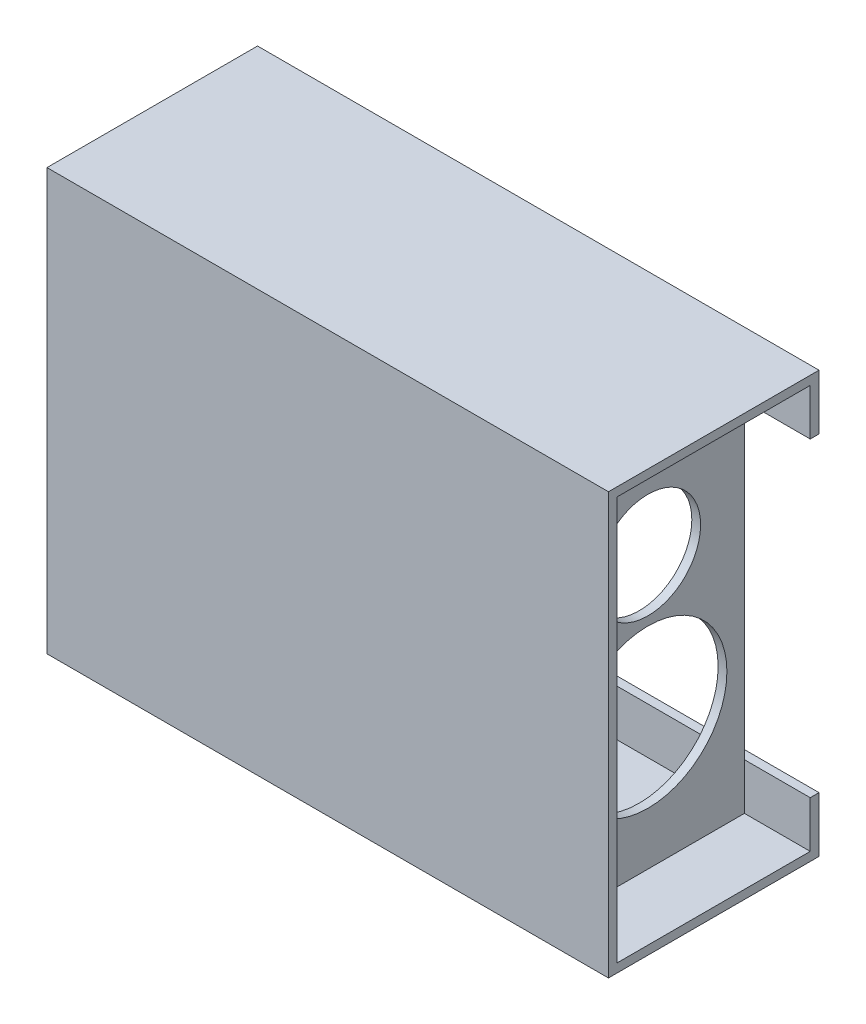
from build123d import *

# Parameters (mm, degrees)
SKETCH2_W                      = 152.4
SKETCH2_H                      = 76.2
BOSS_EXTRUDE1_DEPTH            = 3.175
SKETCH3_W                      = 152.4
SKETCH3_H                      = 76.2
SKETCH3_W_2                    = 146.05
SKETCH3_H_2                    = 69.85
BOSS_EXTRUDE2_DEPTH            = 71.4375
SKETCH4_W                      = 152.4
SKETCH4_H                      = 76.2
BOSS_EXTRUDE3_DEPTH            = 3.175
SKETCH5_W                      = 152.4
SKETCH5_H                      = 76.2
SKETCH5_W_2                    = 146.05
SKETCH5_H_2                    = 69.85
BOSS_EXTRUDE4_DEPTH            = 98.425
F_97_1_DIAMETER_HOLE1_D        = 25.4
F_97_1_5_DIAMETER_HOLE1_D      = 38.1
F_97_1_5_DIAMETER_HOLE1_DEPTH  = 6.35
SKETCH6_W                      = 152.4
SKETCH6_H                      = 76.2
BOSS_EXTRUDE6_DEPTH            = 3.175
F_97_1_5_DIAMETER_HOLE2_D      = 38.1
F_97_1_5_DIAMETER_HOLE2_DEPTH  = 6.35
F_97_2_25_DIAMETER_HOLE1_D     = 57.15
F_97_2_25_DIAMETER_HOLE1_DEPTH = 6.35
SKETCH16_W                     = 152.4
SKETCH16_H                     = 76.2
SKETCH16_W_2                   = 146.05
SKETCH16_H_2                   = 69.85
BOSS_EXTRUDE7_DEPTH            = 23.8125
SKETCH17_W                     = 188.2
SKETCH17_H                     = 112.4
CUT_EXTRUDE1_DEPTH             = 3.175


with BuildPart() as part:
    # Sketch2 → Boss-Extrude1 (new body)
    with BuildSketch(Plane.YZ):
        with Locations((5.965836299, -2.847330961)):
            Rectangle(SKETCH2_W, SKETCH2_H)
    extrude(amount=BOSS_EXTRUDE1_DEPTH)

    # Sketch3 → Boss-Extrude2 (add)
    with BuildSketch(Plane.YZ.offset(3.175)):
        with Locations((5.965836299, -2.847330961)):
            Rectangle(SKETCH3_W, SKETCH3_H)
        with Locations((5.965836299, -2.847330961)):
            Rectangle(SKETCH3_W_2, SKETCH3_H_2, mode=Mode.SUBTRACT)
    extrude(amount=BOSS_EXTRUDE2_DEPTH)

    # Sketch4 → Boss-Extrude3 (add)
    with BuildSketch(Plane.YZ.offset(74.6125)):
        with Locations((5.965836299, -2.847330961)):
            Rectangle(SKETCH4_W, SKETCH4_H)
    extrude(amount=BOSS_EXTRUDE3_DEPTH)

    # Sketch5 → Boss-Extrude4 (add)
    with BuildSketch(Plane.YZ.offset(77.7875)):
        with Locations((5.965836299, -2.847330961)):
            Rectangle(SKETCH5_W, SKETCH5_H)
        with Locations((5.965836299, -2.847330961)):
            Rectangle(SKETCH5_W_2, SKETCH5_H_2, mode=Mode.SUBTRACT)
    extrude(amount=BOSS_EXTRUDE4_DEPTH)

    # #97 (1) Diameter Hole1 (through all)
    with Locations(Plane.YZ.offset(77.7875)):
        with Locations((-19.434163701, -2.847330961), (31.365836299, -2.847330961)):
            Hole(F_97_1_DIAMETER_HOLE1_D / 2)

    # #97 (1.5) Diameter Hole1
    with Locations(Plane(origin=(0, 0, 0), x_dir=(0, -1, 0), z_dir=(-1, 0, 0))):
        with Locations((-31.365836299, -2.847330961)):
            Hole(F_97_1_5_DIAMETER_HOLE1_D / 2, depth=F_97_1_5_DIAMETER_HOLE1_DEPTH)

    # Sketch6 → Boss-Extrude6 (add)
    with BuildSketch(Plane.YZ.offset(176.2125)):
        with Locations((5.965836299, -2.847330961)):
            Rectangle(SKETCH6_W, SKETCH6_H)
    extrude(amount=BOSS_EXTRUDE6_DEPTH)

    # #97 (1.5) Diameter Hole2
    with Locations(Plane.YZ.offset(179.3875)):
        with Locations((31.365836299, -2.847330961)):
            Hole(F_97_1_5_DIAMETER_HOLE2_D / 2, depth=F_97_1_5_DIAMETER_HOLE2_DEPTH)

    # #97 (2.25) Diameter Hole1
    with Locations(Plane.YZ.offset(179.3875)):
        with Locations((-19.434163701, -2.847330961)):
            Hole(F_97_2_25_DIAMETER_HOLE1_D / 2, depth=F_97_2_25_DIAMETER_HOLE1_DEPTH)

    # Sketch16 → Boss-Extrude7 (add)
    with BuildSketch(Plane.YZ.offset(179.3875)):
        with Locations((5.965836299, -2.847330961)):
            Rectangle(SKETCH16_W, SKETCH16_H)
        with Locations((5.965836299, -2.847330961)):
            Rectangle(SKETCH16_W_2, SKETCH16_H_2, mode=Mode.SUBTRACT)
    extrude(amount=BOSS_EXTRUDE7_DEPTH)

    # Sketch17 → Cut-Extrude1 (cut)
    with BuildSketch(Plane(origin=(0, 0, -40.947330961), x_dir=(1, 0, 0), z_dir=(0, 0, -1))):
        with Locations((109.1, -5.965836299)):
            Rectangle(SKETCH17_W, SKETCH17_H)
    extrude(amount=-CUT_EXTRUDE1_DEPTH, mode=Mode.SUBTRACT)


solid = part.part
